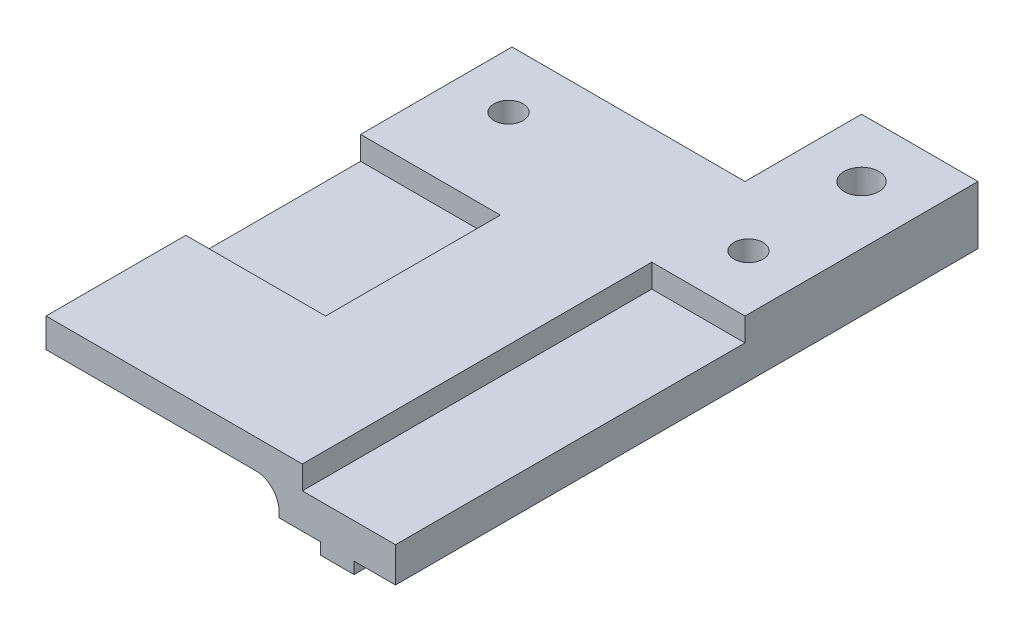
from build123d import *

# Parameters (mm, degrees)
BOSS_EXTRUDE1_DEPTH = 50
SKETCH2_R           = 1.25
CUT_EXTRUDE1_DEPTH  = 7
SKETCH3_W           = 8
SKETCH3_H           = 30
SKETCH3_W_2         = 12
SKETCH3_H_2         = 15
CUT_EXTRUDE2_DEPTH  = 2
SKETCH4_R           = 1.5
SKETCH4_W           = 20
SKETCH4_H           = 10
CUT_EXTRUDE3_DEPTH  = 7
FILLET1_R           = 2


with BuildPart() as part:
    # Sketch1 → Boss-Extrude1 (new body)
    with BuildSketch(Plane.XY):
        Polygon((15, 0), (15, -5), (11.45, -5), (11.45, -6), (8.55, -6), (8.55, -5), (5, -5), (5, -2.5), (-15, -2.5), (-15, 0), align=None)
    extrude(amount=BOSS_EXTRUDE1_DEPTH)

    # Sketch2 → Cut-Extrude1 (cut, through all)
    with BuildSketch(Plane(origin=(0, 0, 0), x_dir=(1, 0, 0), z_dir=(0, 1, 0))):
        with Locations((-10.3, -15)):
            Circle(SKETCH2_R)
        with Locations((10.3, -15)):
            Circle(SKETCH2_R)
    extrude(amount=-CUT_EXTRUDE1_DEPTH, mode=Mode.SUBTRACT)

    # Sketch3 → Cut-Extrude2 (cut)
    with BuildSketch(Plane(origin=(0, 0, 0), x_dir=(1, 0, 0), z_dir=(0, 1, 0))):
        with Locations((11, -35)):
            Rectangle(SKETCH3_W, SKETCH3_H)
        with Locations((-9, -30.5)):
            Rectangle(SKETCH3_W_2, SKETCH3_H_2)
    extrude(amount=-CUT_EXTRUDE2_DEPTH, mode=Mode.SUBTRACT)

    # Sketch4 → Cut-Extrude3 (cut, through all)
    with BuildSketch(Plane(origin=(0, -6, 0), x_dir=(-1, 0, 0), z_dir=(0, -1, 0))):
        with Locations((-10, -5)):
            Circle(SKETCH4_R)
        with Locations((5, -5)):
            Rectangle(SKETCH4_W, SKETCH4_H)
    extrude(amount=-CUT_EXTRUDE3_DEPTH, mode=Mode.SUBTRACT)

    # Fillet1
    fillet1_edges = [part.edges().sort_by_distance(p)[0] for p in [
        (5, -2.5, 30),
    ]]
    fillet(fillet1_edges, radius=FILLET1_R)


solid = part.part
